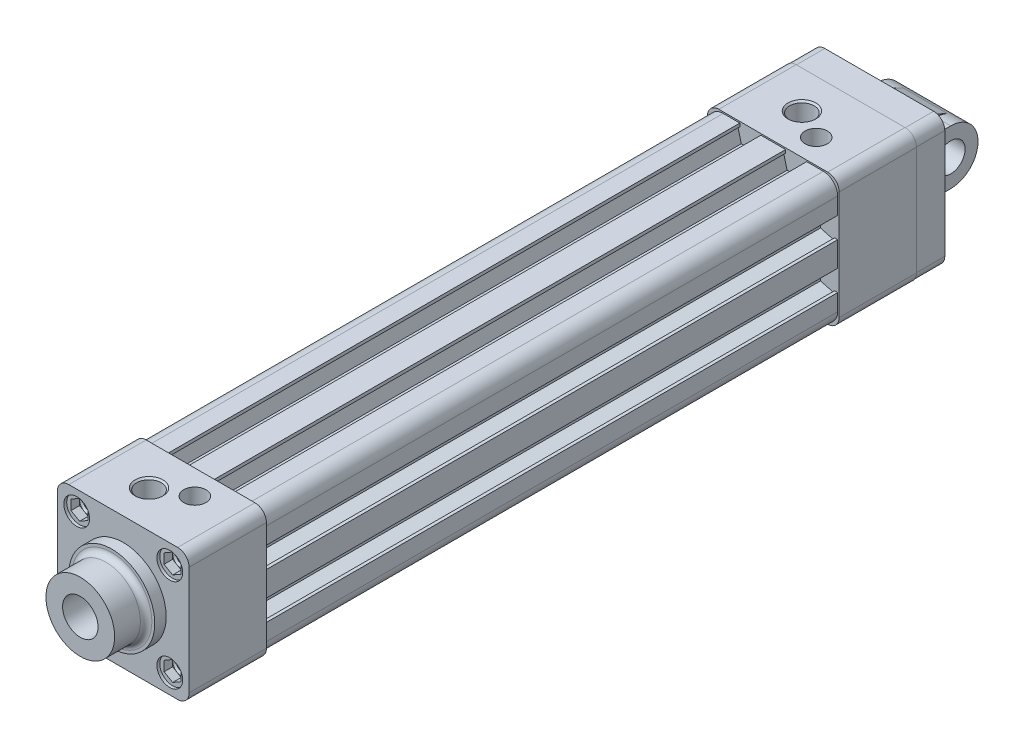
from build123d import *

# Parameters (mm, degrees)
BOSS_EXTRUDE1_DEPTH      = 27
BOSS_EXTRUDE2_DEPTH      = 200
BOSS_EXTRUDE3_DEPTH      = 27
CUT_EXTRUDE1_DEPTH       = 4
CUT_EXTRUDE2_DEPTH       = 4
CUT_EXTRUDE3_DEPTH       = 4
CUT_EXTRUDE4_DEPTH       = 4
CUT_EXTRUDE5_DEPTH       = 4
CUT_EXTRUDE6_DEPTH       = 4
CUT_EXTRUDE7_DEPTH       = 4
CUT_EXTRUDE8_DEPTH       = 4
SKETCH21_W               = 3.9
SKETCH21_H               = 6.75
CUT_EXTRUDE9_DEPTH       = 2.5
SKETCH24_W               = 3.9
SKETCH24_H               = 6.75
BOSS_EXTRUDE4_DEPTH      = 10
BOSS_EXTRUDE5_DEPTH      = 7.8
BOSS_EXTRUDE5_DEPTH_BACK = 7.8
BOSS_EXTRUDE6_DEPTH      = 13
BOSS_EXTRUDE6_DEPTH_BACK = 13
SKETCH28_R               = 5
CUT_EXTRUDE10_DEPTH      = 14
CUT_EXTRUDE10_DEPTH_BACK = 14
SKETCH30_R               = 6.2
CUT_EXTRUDE11_DEPTH      = 162


with BuildPart() as part:
    # Sketch1 → Boss-Extrude1 (new body)
    with BuildSketch(Plane.XY.offset(-254)):
        with BuildLine():
            Line((-19, -23), (19, -23))
            ThreePointArc((19, -23), (21.828427125, -21.828427125), (23, -19))
            Line((23, -19), (23, 19))
            ThreePointArc((23, 19), (21.828427125, 21.828427125), (19, 23))
            Line((19, 23), (-19, 23))
            ThreePointArc((-19, 23), (-21.828427125, 21.828427125), (-23, 19))
            Line((-23, 19), (-23, -19))
            ThreePointArc((-23, -19), (-21.828427125, -21.828427125), (-19, -23))
        make_face()
    extrude(amount=BOSS_EXTRUDE1_DEPTH)

    # Sketch2 → Boss-Extrude2 (add)
    with BuildSketch(Plane.XY.offset(-227)):
        with BuildLine():
            Line((-17.5, -22.5), (-11.675, -22.5))
            Line((-11.675, -22.5), (-11.675, -21.393043531))
            Line((-11.675, -21.393043531), (-12.355771366, -21))
            Line((-12.355771366, -21), (-11.15, -16.5))
            Line((-11.15, -16.5), (-4.85, -16.5))
            Line((-4.85, -16.5), (-3.644228634, -21))
            Line((-3.644228634, -21), (-4.325, -21.393043531))
            Line((-4.325, -21.393043531), (-4.325, -22.5))
            Line((-4.325, -22.5), (4.325, -22.5))
            Line((4.325, -22.5), (4.325, -21.393043531))
            Line((4.325, -21.393043531), (3.644228634, -21))
            Line((3.644228634, -21), (4.85, -16.5))
            Line((4.85, -16.5), (11.15, -16.5))
            Line((11.15, -16.5), (12.355771366, -21))
            Line((12.355771366, -21), (11.675, -21.393043531))
            Line((11.675, -21.393043531), (11.675, -22.5))
            Line((11.675, -22.5), (17.5, -22.5))
            ThreePointArc((17.5, -22.5), (21.035533906, -21.035533906), (22.5, -17.5))
            Line((22.5, -17.5), (22.5, -11.675))
            Line((22.5, -11.675), (21.393043531, -11.675))
            Line((21.393043531, -11.675), (21, -12.355771366))
            Line((21, -12.355771366), (16.5, -11.15))
            Line((16.5, -11.15), (16.5, -4.85))
            Line((16.5, -4.85), (21, -3.644228634))
            Line((21, -3.644228634), (21.393043531, -4.325))
            Line((21.393043531, -4.325), (22.5, -4.325))
            Line((22.5, -4.325), (22.5, 4.325))
            Line((22.5, 4.325), (21.393043531, 4.325))
            Line((21.393043531, 4.325), (21, 3.644228634))
            Line((21, 3.644228634), (16.5, 4.85))
            Line((16.5, 4.85), (16.5, 11.15))
            Line((16.5, 11.15), (21, 12.355771366))
            Line((21, 12.355771366), (21.393043531, 11.675))
            Line((21.393043531, 11.675), (22.5, 11.675))
            Line((22.5, 11.675), (22.5, 17.5))
            ThreePointArc((22.5, 17.5), (21.035533906, 21.035533906), (17.5, 22.5))
            Line((17.5, 22.5), (11.675, 22.5))
            Line((11.675, 22.5), (11.675, 21.393043531))
            Line((11.675, 21.393043531), (12.355771366, 21))
            Line((12.355771366, 21), (11.15, 16.5))
            Line((11.15, 16.5), (4.85, 16.5))
            Line((4.85, 16.5), (3.644228634, 21))
            Line((3.644228634, 21), (4.325, 21.393043531))
            Line((4.325, 21.393043531), (4.325, 22.5))
            Line((4.325, 22.5), (-4.325, 22.5))
            Line((-4.325, 22.5), (-4.325, 21.393043531))
            Line((-4.325, 21.393043531), (-3.644228634, 21))
            Line((-3.644228634, 21), (-4.85, 16.5))
            Line((-4.85, 16.5), (-11.15, 16.5))
            Line((-11.15, 16.5), (-12.355771366, 21))
            Line((-12.355771366, 21), (-11.675, 21.393043531))
            Line((-11.675, 21.393043531), (-11.675, 22.5))
            Line((-11.675, 22.5), (-17.5, 22.5))
            ThreePointArc((-17.5, 22.5), (-21.035533906, 21.035533906), (-22.5, 17.5))
            Line((-22.5, 17.5), (-22.5, 11.675))
            Line((-22.5, 11.675), (-21.393043531, 11.675))
            Line((-21.393043531, 11.675), (-21, 12.355771366))
            Line((-21, 12.355771366), (-16.5, 11.15))
            Line((-16.5, 11.15), (-16.5, 4.85))
            Line((-16.5, 4.85), (-21, 3.644228634))
            Line((-21, 3.644228634), (-21.393043531, 4.325))
            Line((-21.393043531, 4.325), (-22.5, 4.325))
            Line((-22.5, 4.325), (-22.5, -4.325))
            Line((-22.5, -4.325), (-21.393043531, -4.325))
            Line((-21.393043531, -4.325), (-21, -3.644228634))
            Line((-21, -3.644228634), (-16.5, -4.85))
            Line((-16.5, -4.85), (-16.5, -11.15))
            Line((-16.5, -11.15), (-21, -12.355771366))
            Line((-21, -12.355771366), (-21.393043531, -11.675))
            Line((-21.393043531, -11.675), (-22.5, -11.675))
            Line((-22.5, -11.675), (-22.5, -17.5))
            ThreePointArc((-22.5, -17.5), (-21.035533906, -21.035533906), (-17.5, -22.5))
        make_face()
    extrude(amount=BOSS_EXTRUDE2_DEPTH)

    # Sketch3 → Boss-Extrude3 (add)
    with BuildSketch(Plane.XY):
        with BuildLine():
            Line((-19, -23), (19, -23))
            ThreePointArc((19, -23), (21.828427125, -21.828427125), (23, -19))
            Line((23, -19), (23, 19))
            ThreePointArc((23, 19), (21.828427125, 21.828427125), (19, 23))
            Line((19, 23), (-19, 23))
            ThreePointArc((-19, 23), (-21.828427125, 21.828427125), (-23, 19))
            Line((-23, 19), (-23, -19))
            ThreePointArc((-23, -19), (-21.828427125, -21.828427125), (-19, -23))
        make_face()
    extrude(amount=-BOSS_EXTRUDE3_DEPTH)

    # Sketch4 → Cut-Extrude1 (cut)
    with BuildSketch(Plane.XY):
        Polygon((13.25, 17.982050808), (13.25, 14.517949192), (16.25, 12.785898385), (19.25, 14.517949192), (19.25, 17.982050808), (16.25, 19.714101615), align=None)
    extrude(amount=-CUT_EXTRUDE1_DEPTH, mode=Mode.SUBTRACT)

    # Sketch5 → Cut-Revolve1 (revolve, cut)
    with BuildSketch(Plane(origin=(16.25, 0, 0), x_dir=(0, 0, -1), z_dir=(1, 0, 0)), mode=Mode.PRIVATE) as cut_revolve1_sk:
        Polygon((17, 16.25), (17, 13.8635), (4.6135, 13.8635), (4, 13.25), (1, 13.25), (1, 11.75), (-1, 11.75), (-1, 16.25), align=None)
    revolve(cut_revolve1_sk.sketch.rotate(Axis((16.25, 16.25, 1), (0, 0, -1)), 90), axis=Axis((16.25, 16.25, 1), (0, 0, -1)), mode=Mode.SUBTRACT)  # turned: the seam where the file's is

    # Sketch6 → Cut-Extrude2 (cut)
    with BuildSketch(Plane.XY):
        Polygon((-19.25, 17.982050808), (-19.25, 14.517949192), (-16.25, 12.785898385), (-13.25, 14.517949192), (-13.25, 17.982050808), (-16.25, 19.714101615), align=None)
    extrude(amount=-CUT_EXTRUDE2_DEPTH, mode=Mode.SUBTRACT)

    # Sketch7 → Cut-Revolve2 (revolve, cut)
    with BuildSketch(Plane(origin=(-16.25, 0, 0), x_dir=(0, 0, -1), z_dir=(1, 0, 0)), mode=Mode.PRIVATE) as cut_revolve2_sk:
        Polygon((17, 16.25), (17, 13.8635), (4.6135, 13.8635), (4, 13.25), (1, 13.25), (1, 11.75), (-1, 11.75), (-1, 16.25), align=None)
    revolve(cut_revolve2_sk.sketch.rotate(Axis((-16.25, 16.25, 1), (0, 0, -1)), 90), axis=Axis((-16.25, 16.25, 1), (0, 0, -1)), mode=Mode.SUBTRACT)  # turned: the seam where the file's is

    # Sketch8 → Cut-Extrude3 (cut)
    with BuildSketch(Plane.XY):
        Polygon((-19.25, -17.982050808), (-16.25, -19.714101615), (-13.25, -17.982050808), (-13.25, -14.517949192), (-16.25, -12.785898385), (-19.25, -14.517949192), align=None)
    extrude(amount=-CUT_EXTRUDE3_DEPTH, mode=Mode.SUBTRACT)

    # Sketch9 → Cut-Revolve3 (revolve, cut)
    with BuildSketch(Plane(origin=(-16.25, 0, 0), x_dir=(0, 0, -1), z_dir=(1, 0, 0)), mode=Mode.PRIVATE) as cut_revolve3_sk:
        Polygon((-1, -16.25), (-1, -11.75), (1, -11.75), (1, -13.25), (4, -13.25), (4.6135, -13.8635), (17, -13.8635), (17, -16.25), align=None)
    revolve(cut_revolve3_sk.sketch.rotate(Axis((-16.25, -16.25, -17), (0, 0, 1)), 270), axis=Axis((-16.25, -16.25, -17), (0, 0, 1)), mode=Mode.SUBTRACT)  # turned: the seam where the file's is

    # Sketch10 → Cut-Extrude4 (cut)
    with BuildSketch(Plane.XY):
        Polygon((13.25, -14.517949192), (13.25, -17.982050808), (16.25, -19.714101615), (19.25, -17.982050808), (19.25, -14.517949192), (16.25, -12.785898385), align=None)
    extrude(amount=-CUT_EXTRUDE4_DEPTH, mode=Mode.SUBTRACT)

    # Sketch11 → Cut-Revolve4 (revolve, cut)
    with BuildSketch(Plane(origin=(16.25, 0, 0), x_dir=(0, 0, -1), z_dir=(1, 0, 0)), mode=Mode.PRIVATE) as cut_revolve4_sk:
        Polygon((-1, -16.25), (-1, -11.75), (1, -11.75), (1, -13.25), (4, -13.25), (4.6135, -13.8635), (17, -13.8635), (17, -16.25), align=None)
    revolve(cut_revolve4_sk.sketch.rotate(Axis((16.25, -16.25, -17), (0, 0, 1)), 270), axis=Axis((16.25, -16.25, -17), (0, 0, 1)), mode=Mode.SUBTRACT)  # turned: the seam where the file's is

    # Sketch12 → Cut-Extrude5 (cut)
    with BuildSketch(Plane.XY.offset(-254)):
        Polygon((13.25, 17.982050808), (13.25, 14.517949192), (16.25, 12.785898385), (19.25, 14.517949192), (19.25, 17.982050808), (16.25, 19.714101615), align=None)
    extrude(amount=CUT_EXTRUDE5_DEPTH, mode=Mode.SUBTRACT)

    # Sketch13 → Cut-Revolve5 (revolve, cut)
    with BuildSketch(Plane(origin=(16.25, 0, 0), x_dir=(0, 0, -1), z_dir=(1, 0, 0)), mode=Mode.PRIVATE) as cut_revolve5_sk:
        Polygon((255, 16.25), (255, 11.75), (253, 11.75), (253, 13.25), (250, 13.25), (249.3865, 13.8635), (237, 13.8635), (237, 16.25), align=None)
    revolve(cut_revolve5_sk.sketch.rotate(Axis((16.25, 16.25, -237), (0, 0, -1)), 90), axis=Axis((16.25, 16.25, -237), (0, 0, -1)), mode=Mode.SUBTRACT)  # turned: the seam where the file's is

    # Sketch14 → Cut-Extrude6 (cut)
    with BuildSketch(Plane.XY.offset(-254)):
        Polygon((-19.25, 17.982050808), (-19.25, 14.517949192), (-16.25, 12.785898385), (-13.25, 14.517949192), (-13.25, 17.982050808), (-16.25, 19.714101615), align=None)
    extrude(amount=CUT_EXTRUDE6_DEPTH, mode=Mode.SUBTRACT)

    # Sketch15 → Cut-Revolve6 (revolve, cut)
    with BuildSketch(Plane(origin=(-16.25, 0, 0), x_dir=(0, 0, -1), z_dir=(1, 0, 0)), mode=Mode.PRIVATE) as cut_revolve6_sk:
        Polygon((255, 16.25), (255, 11.75), (253, 11.75), (253, 13.25), (250, 13.25), (249.3865, 13.8635), (237, 13.8635), (237, 16.25), align=None)
    revolve(cut_revolve6_sk.sketch.rotate(Axis((-16.25, 16.25, -237), (0, 0, -1)), 90), axis=Axis((-16.25, 16.25, -237), (0, 0, -1)), mode=Mode.SUBTRACT)  # turned: the seam where the file's is

    # Sketch16 → Cut-Extrude7 (cut)
    with BuildSketch(Plane.XY.offset(-254)):
        Polygon((13.25, -14.517949192), (13.25, -17.982050808), (16.25, -19.714101615), (19.25, -17.982050808), (19.25, -14.517949192), (16.25, -12.785898385), align=None)
    extrude(amount=CUT_EXTRUDE7_DEPTH, mode=Mode.SUBTRACT)

    # Sketch17 → Cut-Revolve7 (revolve, cut)
    with BuildSketch(Plane(origin=(16.25, 0, 0), x_dir=(0, 0, -1), z_dir=(1, 0, 0)), mode=Mode.PRIVATE) as cut_revolve7_sk:
        Polygon((237, -16.25), (237, -13.8635), (249.3865, -13.8635), (250, -13.25), (253, -13.25), (253, -11.75), (255, -11.75), (255, -16.25), align=None)
    revolve(cut_revolve7_sk.sketch.rotate(Axis((16.25, -16.25, -255), (0, 0, 1)), 270), axis=Axis((16.25, -16.25, -255), (0, 0, 1)), mode=Mode.SUBTRACT)  # turned: the seam where the file's is

    # Sketch18 → Cut-Extrude8 (cut)
    with BuildSketch(Plane.XY.offset(-254)):
        Polygon((-19.25, -14.517949192), (-19.25, -17.982050808), (-16.25, -19.714101615), (-13.25, -17.982050808), (-13.25, -14.517949192), (-16.25, -12.785898385), align=None)
    extrude(amount=CUT_EXTRUDE8_DEPTH, mode=Mode.SUBTRACT)

    # Sketch19 → Cut-Revolve8 (revolve, cut)
    with BuildSketch(Plane(origin=(-16.25, 0, 0), x_dir=(0, 0, -1), z_dir=(1, 0, 0)), mode=Mode.PRIVATE) as cut_revolve8_sk:
        Polygon((237, -16.25), (237, -13.8635), (249.3865, -13.8635), (250, -13.25), (253, -13.25), (253, -11.75), (255, -11.75), (255, -16.25), align=None)
    revolve(cut_revolve8_sk.sketch.rotate(Axis((-16.25, -16.25, -255), (0, 0, 1)), 270), axis=Axis((-16.25, -16.25, -255), (0, 0, 1)), mode=Mode.SUBTRACT)  # turned: the seam where the file's is

    # Sketch20 → Cut-Revolve9 (revolve, cut)
    with BuildSketch(Plane(origin=(-4, 0, 0), x_dir=(0, 0, -1), z_dir=(1, 0, 0)), mode=Mode.PRIVATE) as cut_revolve9_sk:
        Polygon((13, 23), (17.864, 23), (17.283, 22.419), (17.283, 10.292791203), (13, 7.82), align=None)
    revolve(cut_revolve9_sk.sketch.rotate(Axis((-4, -50, -13), (0, 1, 0)), 180), axis=Axis((-4, -50, -13), (0, 1, 0)), mode=Mode.SUBTRACT)  # turned: the seam where the file's is

    # Sketch21 → Cut-Revolve10 (revolve, cut)
    with BuildSketch(Plane(origin=(6.5, 0, 0), x_dir=(0, 0, -1), z_dir=(1, 0, 0)), mode=Mode.PRIVATE) as cut_revolve10_sk:
        with Locations((20.45, 19.625)):
            Rectangle(SKETCH21_W, SKETCH21_H)
    revolve(cut_revolve10_sk.sketch.rotate(Axis((6.5, 16.25, -18.5), (0, 1, 0)), 180), axis=Axis((6.5, 16.25, -18.5), (0, 1, 0)), mode=Mode.SUBTRACT)  # turned: the seam where the file's is

    # Sketch22 → Cut-Extrude9 (cut)
    with BuildSketch(Plane(origin=(0, 16.25, 0), x_dir=(-1, 0, 0), z_dir=(0, 1, 0))):
        Polygon((-5.778312164, -17.25), (-7.221687836, -17.25), (-7.943375673, -18.5), (-7.221687836, -19.75), (-5.778312164, -19.75), (-5.056624327, -18.5), align=None)
    extrude(amount=-CUT_EXTRUDE9_DEPTH, mode=Mode.SUBTRACT)

    # Sketch23 → Cut-Revolve11 (revolve, cut)
    with BuildSketch(Plane(origin=(-4, 0, 0), x_dir=(0, 0, -1), z_dir=(1, 0, 0)), mode=Mode.PRIVATE) as cut_revolve11_sk:
        Polygon((241, 23), (245.864, 23), (245.283, 22.419), (245.283, 10.292791203), (241, 7.82), align=None)
    revolve(cut_revolve11_sk.sketch.rotate(Axis((-4, -50, -241), (0, 1, 0)), 180), axis=Axis((-4, -50, -241), (0, 1, 0)), mode=Mode.SUBTRACT)  # turned: the seam where the file's is

    # Sketch24 → Cut-Revolve12 (revolve, cut)
    with BuildSketch(Plane(origin=(6.5, 0, 0), x_dir=(0, 0, -1), z_dir=(1, 0, 0)), mode=Mode.PRIVATE) as cut_revolve12_sk:
        with Locations((237.45, 19.625)):
            Rectangle(SKETCH24_W, SKETCH24_H)
    revolve(cut_revolve12_sk.sketch.rotate(Axis((6.5, 16.25, -235.5), (0, 1, 0)), 180), axis=Axis((6.5, 16.25, -235.5), (0, 1, 0)), mode=Mode.SUBTRACT)  # turned: the seam where the file's is

    # Sketch25 → Boss-Extrude4 (add)
    with BuildSketch(Plane.XY.offset(-254)):
        with BuildLine():
            Line((-19, -22.9), (19, -22.9))
            ThreePointArc((19, -22.9), (21.757716447, -21.757716447), (22.9, -19))
            Line((22.9, -19), (22.9, 19))
            ThreePointArc((22.9, 19), (21.757716447, 21.757716447), (19, 22.9))
            Line((19, 22.9), (-19, 22.9))
            ThreePointArc((-19, 22.9), (-21.757716447, 21.757716447), (-22.9, 19))
            Line((-22.9, 19), (-22.9, -19))
            ThreePointArc((-22.9, -19), (-21.757716447, -21.757716447), (-19, -22.9))
        make_face()
    extrude(amount=-BOSS_EXTRUDE4_DEPTH)

    # Sketch26 → Boss-Extrude5 (add, two sides)
    with BuildSketch(Plane(origin=(0, 0, 0), x_dir=(0, 0, -1), z_dir=(1, 0, 0))) as boss_extrude5_sk:
        with BuildLine():
            Line((264, -16.1), (280.024674039, -8.60534711))
            ThreePointArc((280.024674039, -8.60534711), (285.5, 0), (280.024674039, 8.60534711))
            Line((280.024674039, 8.60534711), (264, 16.1))
            Line((264, 16.1), (264, -16.1))
        make_face()
    extrude(amount=BOSS_EXTRUDE5_DEPTH)
    extrude(boss_extrude5_sk.sketch, amount=-BOSS_EXTRUDE5_DEPTH_BACK)

    # Sketch27 → Boss-Extrude6 (add, two sides)
    with BuildSketch(Plane(origin=(0, 0, 0), x_dir=(0, 0, -1), z_dir=(1, 0, 0))) as boss_extrude6_sk:
        with BuildLine():
            Line((263, -9.5), (276, -9.5))
            ThreePointArc((276, -9.5), (285.5, 0), (276, 9.5))
            Line((276, 9.5), (263, 9.5))
            Line((263, 9.5), (263, -9.5))
        make_face()
    extrude(amount=BOSS_EXTRUDE6_DEPTH)
    extrude(boss_extrude6_sk.sketch, amount=-BOSS_EXTRUDE6_DEPTH_BACK)

    # Sketch28 → Cut-Extrude10 (cut, two sides)
    with BuildSketch(Plane(origin=(0, 0, 0), x_dir=(0, 0, -1), z_dir=(1, 0, 0))) as cut_extrude10_sk:
        with Locations((276, 0)):
            Circle(SKETCH28_R)
    extrude(amount=CUT_EXTRUDE10_DEPTH, mode=Mode.SUBTRACT)
    extrude(cut_extrude10_sk.sketch, amount=-CUT_EXTRUDE10_DEPTH_BACK, mode=Mode.SUBTRACT)

    # Sketch29 → Revolve1 (revolve)
    with BuildSketch(Plane(origin=(0, 0, 0), x_dir=(0, 0, -1), z_dir=(1, 0, 0)), mode=Mode.PRIVATE) as revolve1_sk:
        with BuildLine():
            Line((-15, 0), (-15, 12))
            Line((-15, 12), (-6, 12))
            ThreePointArc((-6, 12), (-4.585786438, 12.585786438), (-4, 14))
            Line((-4, 14), (-4, 15))
            Line((-4, 15), (0, 15))
            Line((0, 15), (0, 0))
            Line((0, 0), (-15, 0))
        make_face()
    revolve(revolve1_sk.sketch.rotate(Axis((0, 0, 0), (0, 0, 1)), 270), axis=Axis((0, 0, 0), (0, 0, 1)))  # turned: the seam where the file's is

    # Sketch30 → Cut-Extrude11 (cut)
    with BuildSketch(Plane.XY.offset(15)):
        Circle(SKETCH30_R)
    extrude(amount=-CUT_EXTRUDE11_DEPTH, mode=Mode.SUBTRACT)


solid = part.part
